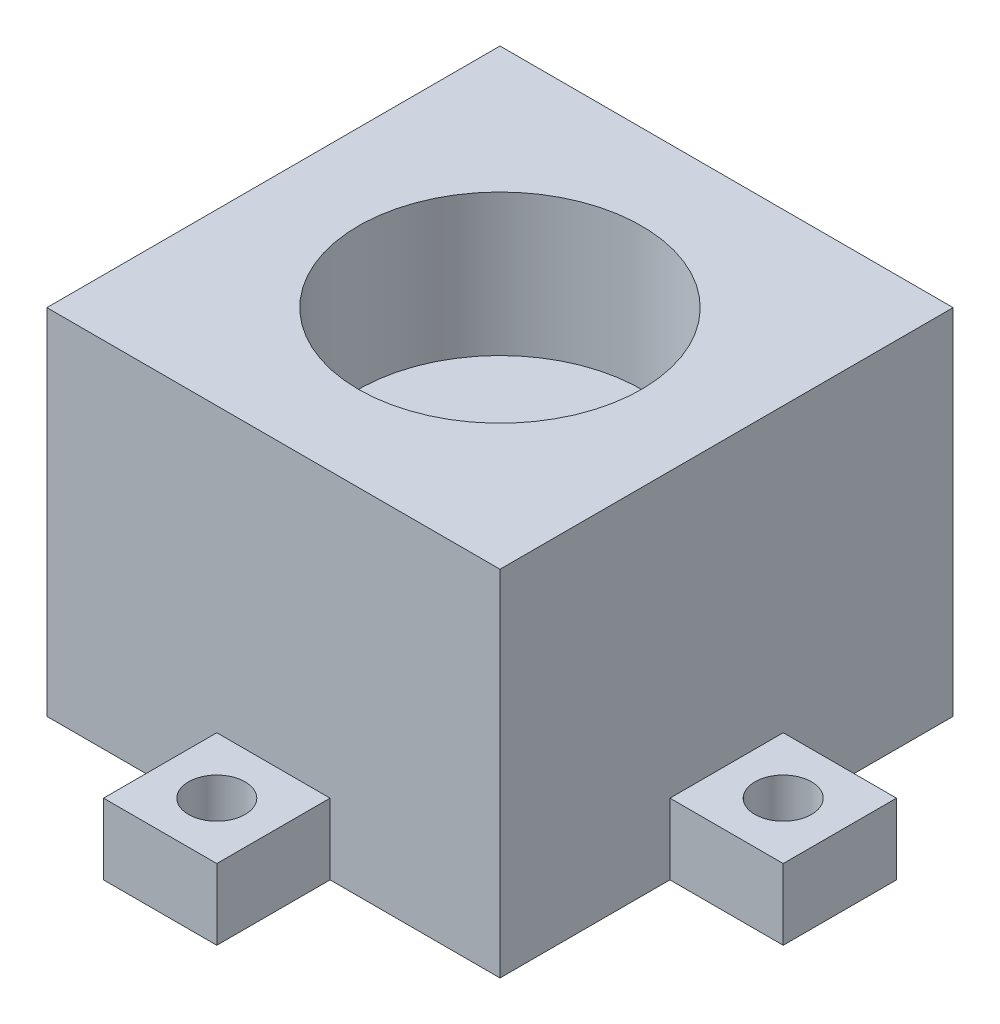
from build123d import *

# Parameters (mm, degrees)
SKETCH1_W           = 10.16
SKETCH1_H           = 10.16
SKETCH1_W_2         = 40.64
SKETCH1_H_2         = 40.64
BOSS_EXTRUDE1_DEPTH = 6.35
SKETCH2_R           = 2.54
CUT_EXTRUDE1_DEPTH  = 8.89
SKETCH3_W           = 40.64
SKETCH3_H           = 40.64
BODY_EXTRUDE_DEPTH  = 25.4
SKETCH4_R           = 12.7
MOTOR_HOLE_DEPTH    = 12.7


with BuildPart() as part:
    # Sketch1 → Boss-Extrude1 (new body)
    with BuildSketch(Plane(origin=(0, 0, 0), x_dir=(1, 0, 0), z_dir=(0, 1, 0))):
        with Locations((-5.08, 20.32)):
            Rectangle(SKETCH1_W, SKETCH1_H)
        with Locations((20.32, 45.72)):
            Rectangle(SKETCH1_W, SKETCH1_H)
        with Locations((20.32, 20.32)):
            Rectangle(SKETCH1_W_2, SKETCH1_H_2)
        with Locations((45.72, 20.32)):
            Rectangle(SKETCH1_W, SKETCH1_H)
        with Locations((20.32, -5.08)):
            Rectangle(SKETCH1_W, SKETCH1_H)
    extrude(amount=BOSS_EXTRUDE1_DEPTH)

    # Sketch2 → Cut-Extrude1 (cut)
    with BuildSketch(Plane(origin=(0, 6.35, 0), x_dir=(1, 0, 0), z_dir=(0, 1, 0))):
        with Locations((-5.08, 20.32)):
            Circle(SKETCH2_R)
        with Locations((20.32, 45.72)):
            Circle(SKETCH2_R)
        with Locations((45.72, 20.32)):
            Circle(SKETCH2_R)
        with Locations((20.32, -5.08)):
            Circle(SKETCH2_R)
    extrude(amount=-CUT_EXTRUDE1_DEPTH, mode=Mode.SUBTRACT)

    # Sketch3 → body_extrude (add)
    with BuildSketch(Plane(origin=(0, 6.35, 0), x_dir=(1, 0, 0), z_dir=(0, 1, 0))):
        with Locations((20.32, 20.32)):
            Rectangle(SKETCH3_W, SKETCH3_H)
    extrude(amount=BODY_EXTRUDE_DEPTH)

    # Sketch4 → motor_hole (cut)
    with BuildSketch(Plane(origin=(0, 31.75, 0), x_dir=(1, 0, 0), z_dir=(0, 1, 0))):
        with Locations((20.32, 20.32)):
            Circle(SKETCH4_R)
    extrude(amount=-MOTOR_HOLE_DEPTH, mode=Mode.SUBTRACT)


solid = part.part
